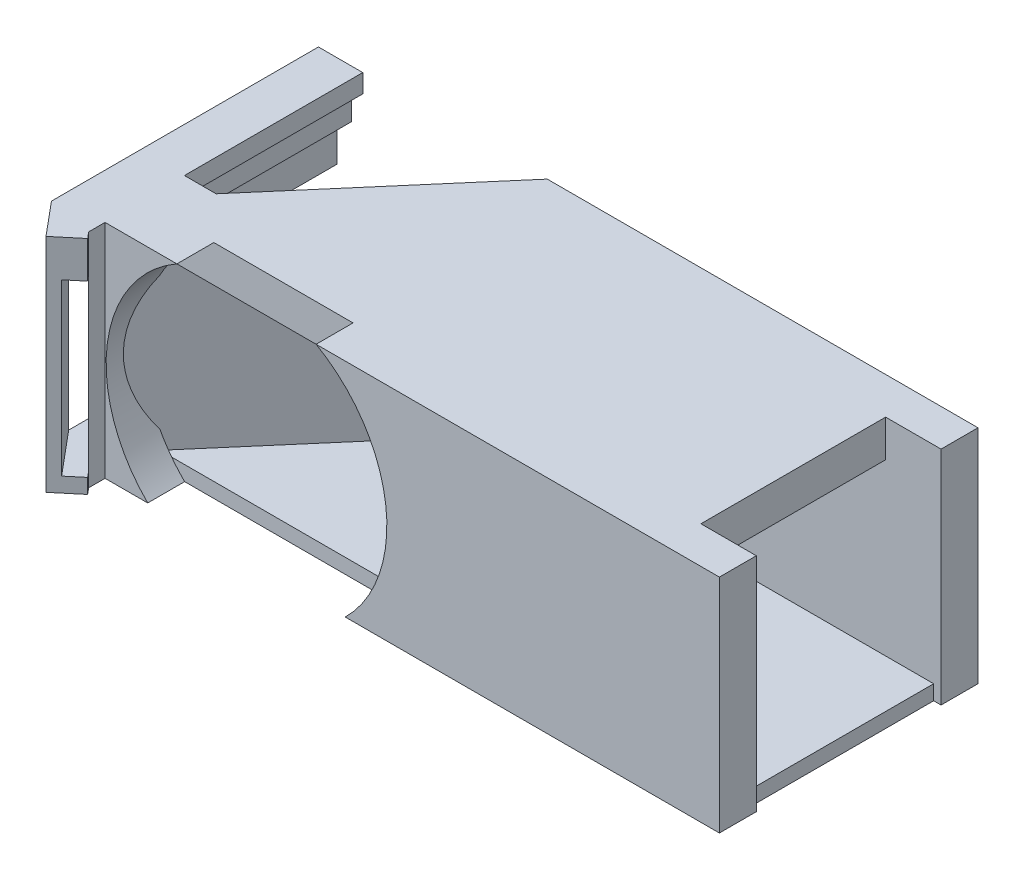
from build123d import *

# Parameters (mm, degrees)
BOSS_EXTRUDE3_DEPTH  = 30
SKETCH6_W            = 25
SKETCH6_H            = 23
CUT_EXTRUDE1_DEPTH   = 86
SKETCH7_W            = 25
SKETCH7_H            = 5
CUT_EXTRUDE2_DEPTH   = 7.5
SKETCH8_W            = 25
SKETCH8_H            = 2
CUT_EXTRUDE3_DEPTH   = 1
SKETCH9_R            = 19
CUT_EXTRUDE4_DEPTH   = 5
BOSS_EXTRUDE4_DEPTH  = 30
SKETCH10_W           = 1.856561782
SKETCH10_H           = 30
BOSS_EXTRUDE5_DEPTH  = 3
BOSS_EXTRUDE6_DEPTH  = 30
SKETCH11_W           = 2.5
SKETCH11_H           = 23
CUT_EXTRUDE5_DEPTH   = 34.579503854
SKETCH12_W           = 29.135235428
SKETCH12_H           = 25
CUT_EXTRUDE6_DEPTH   = 3.5
SKETCH13_W           = 19.135235428
SKETCH13_H           = 5
CUT_EXTRUDE7_DEPTH   = 3.5
SKETCH14_W           = 29.135235428
SKETCH14_H           = 4
BOSS_EXTRUDE7_DEPTH  = 2
SKETCH16_W           = 29.135235428
SKETCH16_H           = 1.5
BOSS_EXTRUDE8_DEPTH  = 2
SKETCH17_W           = 2.551467674
SKETCH17_H           = 30
BOSS_EXTRUDE9_DEPTH  = 5
BOSS_EXTRUDE10_REACH = 85.266
SKETCH18_W           = 29.135235428
SKETCH18_H           = 2.5
SKETCH19_W           = 2.48850009
SKETCH19_H           = 23
BOSS_EXTRUDE11_DEPTH = 2
CUT_EXTRUDE8_START   = -2.4885
SKETCH20_W           = 2
SKETCH20_H           = 23
CUT_EXTRUDE8_DEPTH   = 21.736568
BOSS_EXTRUDE12_REACH = 82.714
SKETCH21_W           = 2.023287715
SKETCH21_H           = 27.5


with BuildPart() as part:
    # Sketch2 → Boss-Extrude3 (new body)
    with BuildSketch(Plane(origin=(0, 0, 0), x_dir=(1, 0, 0), z_dir=(0, 1, 0))):
        Polygon((-105.912162162, 13.018018018), (-20.912162162, 13.018018018), (-20.912162162, 48.018018018), (-75.912162162, 48.018018018), align=None)
    extrude(amount=BOSS_EXTRUDE3_DEPTH)

    # Sketch6 → Cut-Extrude1 (cut, through all)
    with BuildSketch(Plane(origin=(-20.912162162, 0, 0), x_dir=(0, 0, -1), z_dir=(1, 0, 0))):
        with Locations((30.518018018, 13.5)):
            Rectangle(SKETCH6_W, SKETCH6_H)
    extrude(amount=-CUT_EXTRUDE1_DEPTH, mode=Mode.SUBTRACT)

    # Sketch7 → Cut-Extrude2 (cut)
    with BuildSketch(Plane(origin=(-20.912162162, 0, 0), x_dir=(0, 0, -1), z_dir=(1, 0, 0))):
        with Locations((30.518018018, 27.5)):
            Rectangle(SKETCH7_W, SKETCH7_H)
    extrude(amount=-CUT_EXTRUDE2_DEPTH, mode=Mode.SUBTRACT)

    # Sketch8 → Cut-Extrude3 (cut)
    with BuildSketch(Plane(origin=(-20.912162162, 0, 0), x_dir=(0, 0, -1), z_dir=(1, 0, 0))):
        with Locations((30.518018018, 1)):
            Rectangle(SKETCH8_W, SKETCH8_H)
    extrude(amount=-CUT_EXTRUDE3_DEPTH, mode=Mode.SUBTRACT)

    # Sketch9 → Cut-Extrude4 (cut)
    with BuildSketch(Plane.XY.offset(-13.018018018)):
        with Locations((-84.912162162, 13.5)):
            Circle(SKETCH9_R)
    extrude(amount=-CUT_EXTRUDE4_DEPTH, mode=Mode.SUBTRACT)

    # Sketch3 → Boss-Extrude4 (add)
    with BuildSketch(Plane(origin=(0, 0, 0), x_dir=(1, 0, 0), z_dir=(0, 1, 0))):
        Polygon((-106.412808957, 7.383361614), (-110.17791555, 11.88278259), (-79.204856611, 48.018018018), (-75.912162162, 48.018018018), (-105.912162162, 13.018018018), (-103.345157358, 9.950366419), align=None)
    extrude(amount=BOSS_EXTRUDE4_DEPTH)

    # Sketch10 → Boss-Extrude5 (add)
    with BuildSketch(Plane.XY.offset(-13.018018018)):
        with Locations((-104.983881271, 15)):
            Rectangle(SKETCH10_W, SKETCH10_H)
    extrude(amount=BOSS_EXTRUDE5_DEPTH)

    # Sketch4 → Boss-Extrude6 (add)
    with BuildSketch(Plane(origin=(0, 0, 0), x_dir=(1, 0, 0), z_dir=(0, 1, 0))):
        Polygon((-110.17791555, 11.88278259), (-110.17791555, 48.018018018), (-104.17791555, 48.018018018), (-104.17791555, 18.88278259), align=None)
    extrude(amount=BOSS_EXTRUDE6_DEPTH)

    # Sketch11 → Cut-Extrude5 (cut, through all)
    with BuildSketch(Plane(origin=(-47.459390138, 0, -56.715466139), x_dir=(0.7669129, 0, -0.641751201), z_dir=(0.641751201, 0, 0.7669129))):
        with Locations((-74.121074711, 13.5)):
            Rectangle(SKETCH11_W, SKETCH11_H)
    extrude(amount=-CUT_EXTRUDE5_DEPTH, mode=Mode.SUBTRACT)

    # Sketch12 → Cut-Extrude6 (cut)
    with BuildSketch(Plane(origin=(-104.17791555, 0, 0), x_dir=(0, 0, -1), z_dir=(1, 0, 0))):
        with Locations((33.450400304, 15)):
            Rectangle(SKETCH12_W, SKETCH12_H)
    extrude(amount=-CUT_EXTRUDE6_DEPTH, mode=Mode.SUBTRACT)

    # Sketch13 → Cut-Extrude7 (cut, through all)
    with BuildSketch(Plane(origin=(-107.67791555, 0, 0), x_dir=(0, 0, -1), z_dir=(1, 0, 0))):
        with Locations((38.450400304, 15)):
            Rectangle(SKETCH13_W, SKETCH13_H)
    extrude(amount=-CUT_EXTRUDE7_DEPTH, mode=Mode.SUBTRACT)

    # Sketch14 → Boss-Extrude7 (add)
    with BuildSketch(Plane(origin=(-107.67791555, 0, 0), x_dir=(0, 0, -1), z_dir=(1, 0, 0))):
        with Locations((33.450400304, 25.5)):
            Rectangle(SKETCH14_W, SKETCH14_H)
    extrude(amount=BOSS_EXTRUDE7_DEPTH)

    # Sketch16 → Boss-Extrude8 (add)
    with BuildSketch(Plane(origin=(-107.67791555, 0, 0), x_dir=(0, 0, -1), z_dir=(1, 0, 0))):
        with Locations((33.450400304, 3.25)):
            Rectangle(SKETCH16_W, SKETCH16_H)
    extrude(amount=BOSS_EXTRUDE8_DEPTH)

    # Sketch17 → Boss-Extrude9 (add)
    with BuildSketch(Plane(origin=(0, 0, -18.88278259), x_dir=(-1, 0, 0), z_dir=(0, 0, -1))):
        with Locations((102.902181713, 15)):
            Rectangle(SKETCH17_W, SKETCH17_H)
    extrude(amount=BOSS_EXTRUDE9_DEPTH)

    # Boss-Extrude10: up to this face of the body (flat: up to its plane)
    boss_extrude10_end = Plane(part.part.faces().sort_by_distance((-90.415652244, 15, -34.938756447))[0])
    # Sketch18 → Boss-Extrude10 (add, up to the picked face)
    with BuildSketch(Plane(origin=(-104.17791555, 0, 0), x_dir=(0, 0, -1), z_dir=(1, 0, 0)), mode=Mode.PRIVATE) as boss_extrude10_sk1:
        with Locations((33.450400304, 1.25)):
            Rectangle(SKETCH18_W, SKETCH18_H)
    boss_extrude10_tool1 = split(extrude(boss_extrude10_sk1.sketch, amount=BOSS_EXTRUDE10_REACH, mode=Mode.PRIVATE), bisect_by=boss_extrude10_end, keep=Keep.BOTH, mode=Mode.PRIVATE)
    add(boss_extrude10_tool1.solids().sort_by_distance((-104.177916, 1.25, -33.4504))[0])

    # Sketch19 → Boss-Extrude11 (add)
    with BuildSketch(Plane(origin=(-67.487678855, 0, -57.846581876), x_dir=(0.650791373, 0, -0.759256602), z_dir=(0.759256602, 0, 0.650791373))):
        with Locations((-31.723015124, 13.5)):
            Rectangle(SKETCH19_W, SKETCH19_H)
    extrude(amount=BOSS_EXTRUDE11_DEPTH)

    # Sketch20 → Cut-Extrude8 (cut)
    with BuildSketch(Plane(origin=(-19.835317387, 0, 23.141203618), x_dir=(-0.759256602, 0, -0.650791373), z_dir=(0.650791373, 0, -0.759256602)).offset(CUT_EXTRUDE8_START)):
        with Locations((87.886522218, 13.5)):
            Rectangle(SKETCH20_W, SKETCH20_H)
    extrude(amount=CUT_EXTRUDE8_DEPTH, mode=Mode.SUBTRACT)

    # Boss-Extrude12: up to this face of the body (flat: up to its plane)
    boss_extrude12_end = Plane(part.part.faces().sort_by_distance((-90.415652244, 16.25, -34.938756447))[0])
    # Sketch21 → Boss-Extrude12 (add, up to the picked face)
    with BuildSketch(Plane(origin=(-101.626447876, 0, 0), x_dir=(0, 0, -1), z_dir=(1, 0, 0)), mode=Mode.PRIVATE) as boss_extrude12_sk1:
        with Locations((22.871138733, 16.25)):
            Rectangle(SKETCH21_W, SKETCH21_H)
    boss_extrude12_tool1 = split(extrude(boss_extrude12_sk1.sketch, amount=BOSS_EXTRUDE12_REACH, mode=Mode.PRIVATE), bisect_by=boss_extrude12_end, keep=Keep.BOTH, mode=Mode.PRIVATE)
    add(boss_extrude12_tool1.solids().sort_by_distance((-101.626448, 16.25, -22.871139))[0])


solid = part.part
